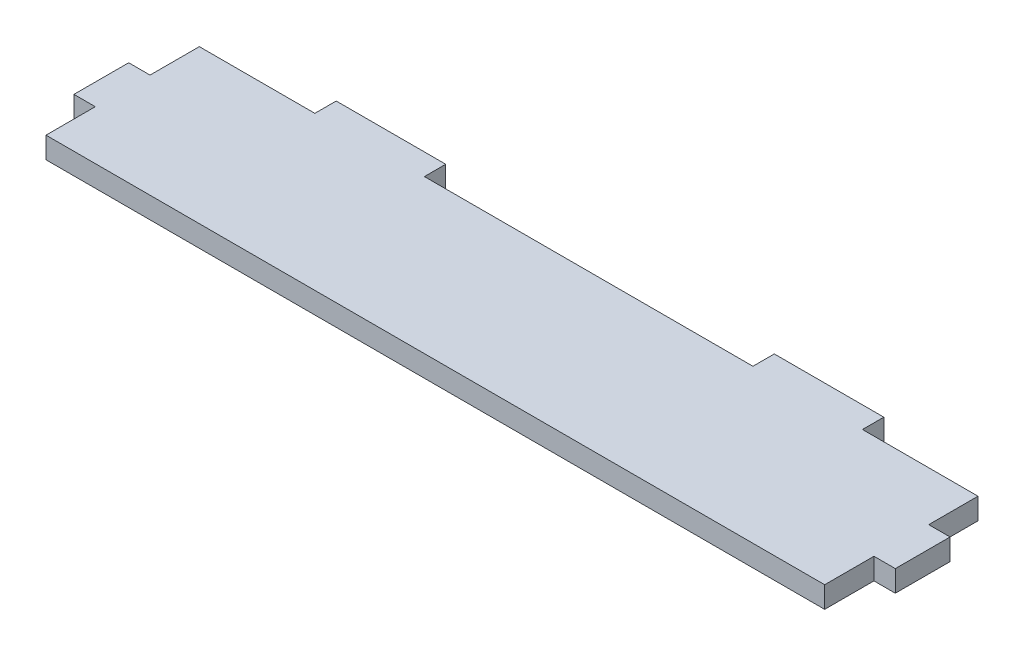
from build123d import *

# Parameters (mm, degrees)
BOSS_EXTRUDE1_DEPTH = 3.9


with BuildPart() as part:
    # Sketch1 → Boss-Extrude1 (new body)
    with BuildSketch(Plane(origin=(0, 0, 0), x_dir=(1, 0, 0), z_dir=(0, 1, 0))):
        Polygon((-71.1, 14), (-50, 14), (-50, 17.9), (-30, 17.9), (-30, 14), (30, 14), (30, 17.9), (50, 17.9), (50, 14), (71.1, 14), (71.1, 5), (75, 5), (75, -5), (71.1, -5), (71.1, -14), (-71.1, -14), (-71.1, -5), (-75, -5), (-75, 5), (-71.1, 5), align=None)
    extrude(amount=BOSS_EXTRUDE1_DEPTH)


solid = part.part
